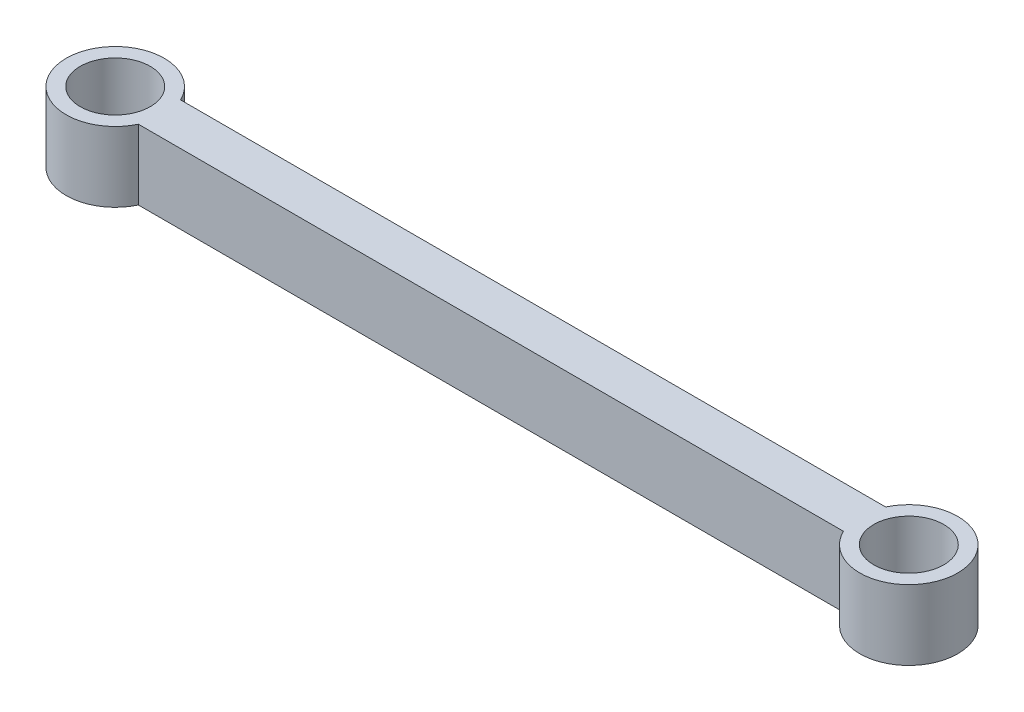
from build123d import *

# Parameters (mm, degrees)
ESQUISSE1_R             = 70
BOSS_EXTRU_2_DEPTH      = 100
ESQUISSE2_R             = 50
ENL_V_MAT_EXTRU_2_DEPTH = 95
ESQUISSE4_R             = 50
ENL_V_MAT_EXTRU_3_DEPTH = 101


with BuildPart() as part:
    # Esquisse1 → Boss.-Extru.2 (new body)
    with BuildSketch(Plane(origin=(0, 0, 0), x_dir=(1, 0, 0), z_dir=(0, 1, 0))):
        with BuildLine():
            Line((1070.306926615, 30.095541494), (63.200145428, 30.095541494))
            ThreePointArc((63.200145428, 30.095541494), (68.278877334, 15.427083652), (70, 0))
            ThreePointArc((70, 0), (68.278877334, -15.427083652), (63.200145428, -30.095541494))
            Line((63.200145428, -30.095541494), (1070.306926615, -30.095541494))
            ThreePointArc((1070.306926615, -30.095541494), (1063.507072043, 0), (1070.306926615, 30.095541494))
        make_face()
        Circle(ESQUISSE1_R)
        with Locations((1133.507072043, 0)):
            Circle(ESQUISSE1_R)
    extrude(amount=BOSS_EXTRU_2_DEPTH)

    # Esquisse2 → Enlèv. mat.-Extru.2 (cut)
    with BuildSketch(Plane(origin=(0, 100, 0), x_dir=(1, 0, 0), z_dir=(0, 1, 0))):
        Circle(ESQUISSE2_R)
    extrude(amount=-ENL_V_MAT_EXTRU_2_DEPTH, mode=Mode.SUBTRACT)

    # Esquisse4 → Enlèv. mat.-Extru.3 (cut, through all)
    with BuildSketch(Plane(origin=(0, 100, 0), x_dir=(1, 0, 0), z_dir=(0, 1, 0))):
        with Locations((1133.507072043, 0)):
            Circle(ESQUISSE4_R)
    extrude(amount=-ENL_V_MAT_EXTRU_3_DEPTH, mode=Mode.SUBTRACT)


solid = part.part
